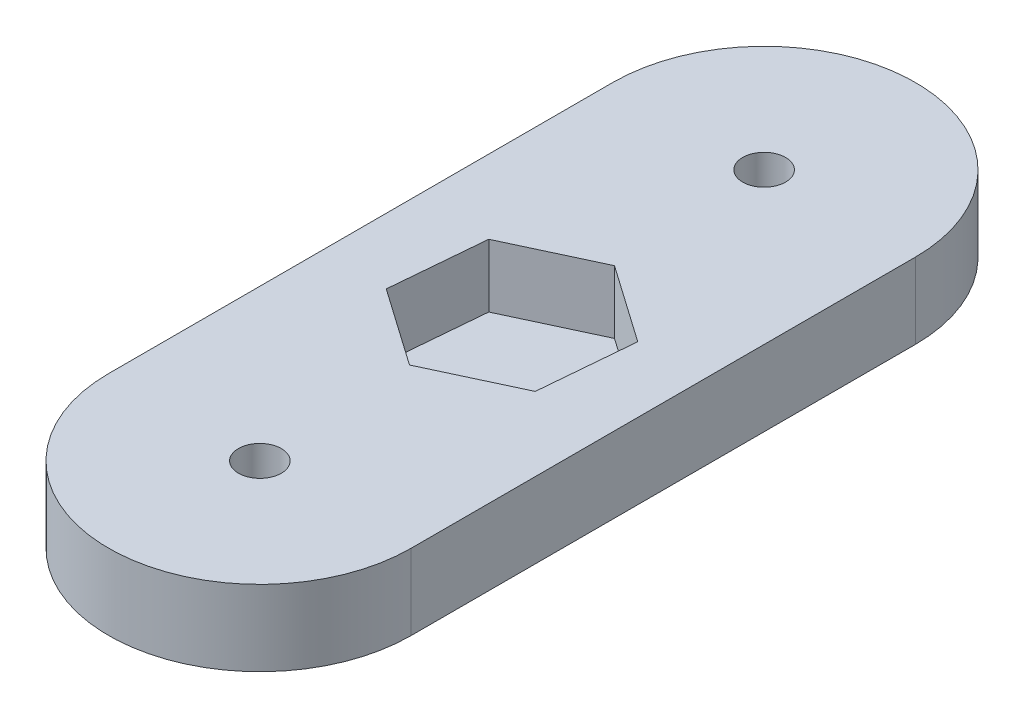
from build123d import *

# Parameters (mm, degrees)
SKETCH1_R           = 1.7
BOSS_EXTRUDE1_DEPTH = 6
CUT_EXTRUDE1_DEPTH  = 5


with BuildPart() as part:
    # Sketch1 → Boss-Extrude1 (new body)
    with BuildSketch(Plane(origin=(0, 0, 0), x_dir=(1, 0, 0), z_dir=(0, 1, 0))):
        with BuildLine():
            Line((-12, 0), (-12, 40))
            ThreePointArc((-12, 40), (0, 52), (12, 40))
            Line((12, 40), (12, 0))
            ThreePointArc((12, 0), (0, -12), (-12, 0))
        make_face()
        with Locations((0, 40)):
            Circle(SKETCH1_R, mode=Mode.SUBTRACT)
        Circle(SKETCH1_R, mode=Mode.SUBTRACT)
    extrude(amount=BOSS_EXTRUDE1_DEPTH)

    # Sketch2 → Cut-Extrude1 (cut)
    with BuildSketch(Plane(origin=(0, 6, 0), x_dir=(1, 0, 0), z_dir=(0, 1, 0))):
        Polygon((6.148189493, 15.694991371), (6.802341583, 23.171983973), (0.65415209, 27.476992602), (-6.148189493, 24.305008629), (-6.802341583, 16.828016027), (-0.65415209, 12.523007398), align=None)
    extrude(amount=-CUT_EXTRUDE1_DEPTH, mode=Mode.SUBTRACT)


solid = part.part
